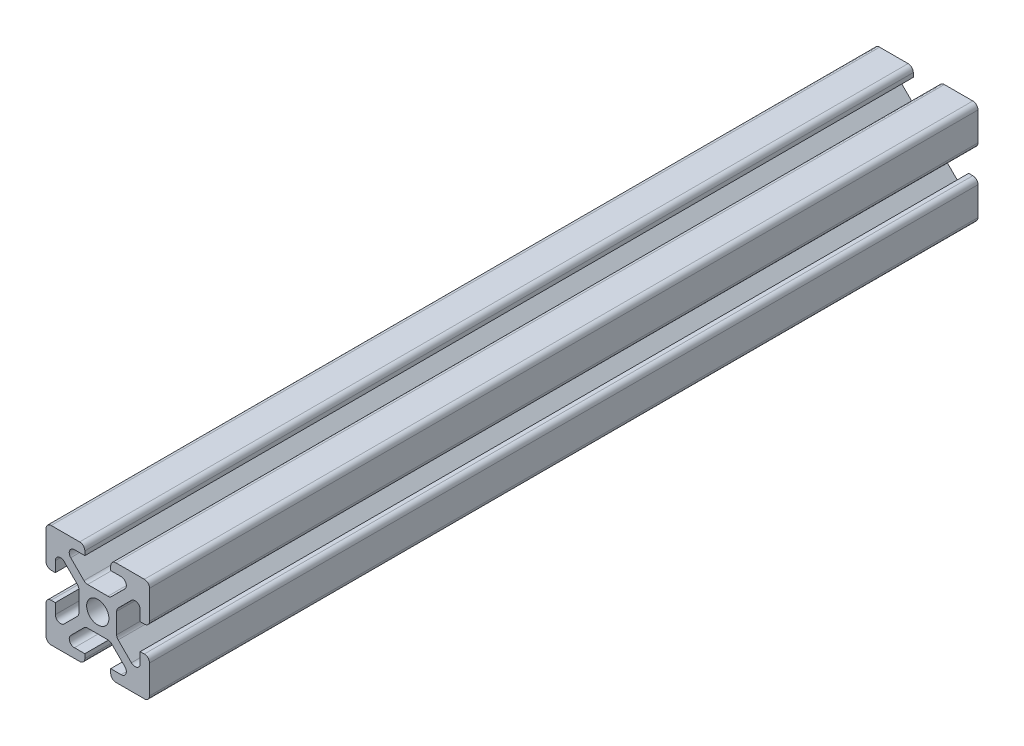
from build123d import *

# Parameters (mm, degrees)
SCHIZZO1_R                   = 2.15
ESTRUSIONE_ESTRUSIONE1_DEPTH = 160


with BuildPart() as part:
    # Schizzo1 → Estrusione-Estrusione1 (new body)
    with BuildSketch(Plane(origin=(0, 0, 0), x_dir=(-1, 0, 0), z_dir=(0, 0, -1))):
        with BuildLine():
            Line((8.2, 2.5), (9, 2.5))
            ThreePointArc((9, 2.5), (9.707106781, 2.792893219), (10, 3.5))
            Line((10, 3.5), (10, 9))
            ThreePointArc((10, 9), (9.707106781, 9.707106781), (9, 10))
            Line((9, 10), (3.5, 10))
            ThreePointArc((3.5, 10), (2.792893219, 9.707106781), (2.5, 9))
            Line((2.5, 9), (2.5, 8.2))
            Line((2.5, 8.2), (4.512994231, 8.2))
            ThreePointArc((4.512994231, 8.2), (5.436873764, 7.582683432), (5.220101013, 6.492893219))
            Line((5.220101013, 6.492893219), (2.670101013, 3.942893219))
            ThreePointArc((2.670101013, 3.942893219), (2.345677664, 3.726120467), (1.962994231, 3.65))
            Line((1.962994231, 3.65), (-1.962994231, 3.65))
            ThreePointArc((-1.962994231, 3.65), (-2.345677664, 3.726120467), (-2.670101013, 3.942893219))
            Line((-2.670101013, 3.942893219), (-5.220101013, 6.492893219))
            ThreePointArc((-5.220101013, 6.492893219), (-5.436873764, 7.582683432), (-4.512994231, 8.2))
            Line((-4.512994231, 8.2), (-2.5, 8.2))
            Line((-2.5, 8.2), (-2.5, 9))
            ThreePointArc((-2.5, 9), (-2.792893219, 9.707106781), (-3.5, 10))
            Line((-3.5, 10), (-9, 10))
            ThreePointArc((-9, 10), (-9.707106781, 9.707106781), (-10, 9))
            Line((-10, 9), (-10, 3.5))
            ThreePointArc((-10, 3.5), (-9.707106781, 2.792893219), (-9, 2.5))
            Line((-9, 2.5), (-8.2, 2.5))
            Line((-8.2, 2.5), (-8.2, 4.512994231))
            ThreePointArc((-8.2, 4.512994231), (-7.582683432, 5.436873764), (-6.492893219, 5.220101013))
            Line((-6.492893219, 5.220101013), (-3.942893219, 2.670101013))
            ThreePointArc((-3.942893219, 2.670101013), (-3.726120467, 2.345677664), (-3.65, 1.962994231))
            Line((-3.65, 1.962994231), (-3.65, -1.962994231))
            ThreePointArc((-3.65, -1.962994231), (-3.726120467, -2.345677664), (-3.942893219, -2.670101013))
            Line((-3.942893219, -2.670101013), (-6.492893219, -5.220101013))
            ThreePointArc((-6.492893219, -5.220101013), (-7.582683432, -5.436873764), (-8.2, -4.512994231))
            Line((-8.2, -4.512994231), (-8.2, -2.5))
            Line((-8.2, -2.5), (-9, -2.5))
            ThreePointArc((-9, -2.5), (-9.707106781, -2.792893219), (-10, -3.5))
            Line((-10, -3.5), (-10, -9))
            ThreePointArc((-10, -9), (-9.707106781, -9.707106781), (-9, -10))
            Line((-9, -10), (-3.5, -10))
            ThreePointArc((-3.5, -10), (-2.792893219, -9.707106781), (-2.5, -9))
            Line((-2.5, -9), (-2.5, -8.2))
            Line((-2.5, -8.2), (-4.512994231, -8.2))
            ThreePointArc((-4.512994231, -8.2), (-5.436873764, -7.582683432), (-5.220101013, -6.492893219))
            Line((-5.220101013, -6.492893219), (-2.670101013, -3.942893219))
            ThreePointArc((-2.670101013, -3.942893219), (-2.345677664, -3.726120467), (-1.962994231, -3.65))
            Line((-1.962994231, -3.65), (1.962994231, -3.65))
            ThreePointArc((1.962994231, -3.65), (2.345677664, -3.726120467), (2.670101013, -3.942893219))
            Line((2.670101013, -3.942893219), (5.220101013, -6.492893219))
            ThreePointArc((5.220101013, -6.492893219), (5.436873764, -7.582683432), (4.512994231, -8.2))
            Line((4.512994231, -8.2), (2.5, -8.2))
            Line((2.5, -8.2), (2.5, -9))
            ThreePointArc((2.5, -9), (2.792893219, -9.707106781), (3.5, -10))
            Line((3.5, -10), (9, -10))
            ThreePointArc((9, -10), (9.707106781, -9.707106781), (10, -9))
            Line((10, -9), (10, -3.5))
            ThreePointArc((10, -3.5), (9.707106781, -2.792893219), (9, -2.5))
            Line((9, -2.5), (8.2, -2.5))
            Line((8.2, -2.5), (8.2, -4.512994231))
            ThreePointArc((8.2, -4.512994231), (7.582683432, -5.436873764), (6.492893219, -5.220101013))
            Line((6.492893219, -5.220101013), (3.942893219, -2.670101013))
            ThreePointArc((3.942893219, -2.670101013), (3.726120467, -2.345677664), (3.65, -1.962994231))
            Line((3.65, -1.962994231), (3.65, 1.962994231))
            ThreePointArc((3.65, 1.962994231), (3.726120467, 2.345677664), (3.942893219, 2.670101013))
            Line((3.942893219, 2.670101013), (6.492893219, 5.220101013))
            ThreePointArc((6.492893219, 5.220101013), (7.582683432, 5.436873764), (8.2, 4.512994231))
            Line((8.2, 4.512994231), (8.2, 2.5))
        make_face()
        Circle(SCHIZZO1_R, mode=Mode.SUBTRACT)
    extrude(amount=-ESTRUSIONE_ESTRUSIONE1_DEPTH)


solid = part.part
